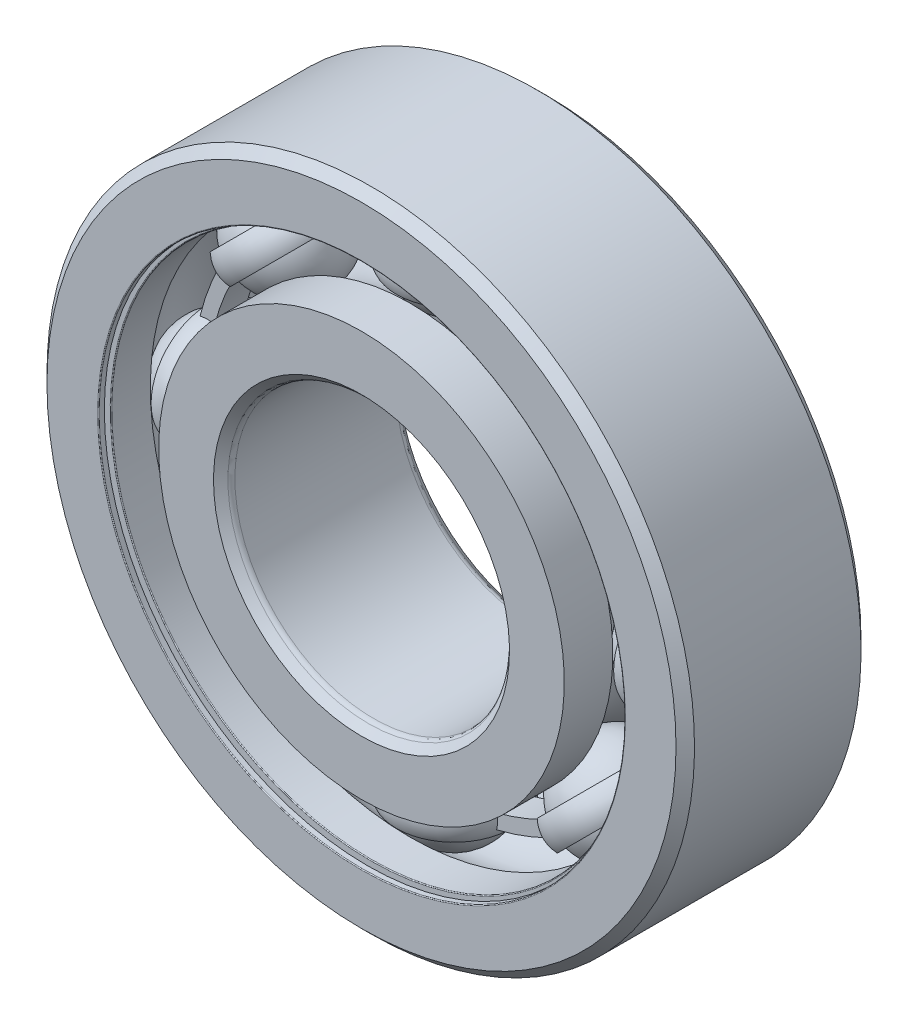
from build123d import *

# Parameters (mm, degrees)
BOSS_EXTRUDE1_DEPTH = 0.666666667
CIRPATTERN1_COUNT   = 8
CIRPATTERN2_COUNT   = 8
FILLET1_R           = 0.036
FILLET2_R           = 0.3


with BuildPart() as part:
    # Sketch3 → Revolve1 (revolve)
    with BuildSketch(Plane(origin=(0, 0, 0), x_dir=(0, 0, -1), z_dir=(1, 0, 0))):
        with BuildLine():
            Line((3.6, 14), (4, 13.6))
            Line((4, 13.6), (4, 11.230769231))
            Line((4, 11.230769231), (1.9, 11.230769231))
            ThreePointArc((1.9, 11.230769231), (0, 12.263800543), (-1.9, 11.230769231))
            Line((-1.9, 11.230769231), (-4, 11.230769231))
            Line((-4, 11.230769231), (-4, 13.6))
            Line((-4, 13.6), (-3.6, 14))
            Line((-3.6, 14), (3.6, 14))
        make_face()
    revolve(axis=Axis((0, 0, 4), (0, 0, -1)))

    # Sketch8 → Cut-Revolve1 (revolve, cut)
    with BuildSketch(Plane(origin=(0, 0, 0), x_dir=(0, 0, -1), z_dir=(1, 0, 0))):
        Polygon((-3.744, 11.230769231), (-3.6, 11.230769231), (-3.6, 12.153846154), (-3.744, 12.153846154), (-3.744, 11.374769231), (-4, 11.374769231), (-4, 11.230769231), align=None)
        Polygon((3.6, 11.230769231), (3.744, 11.230769231), (4, 11.230769231), (4, 11.374769231), (3.744, 11.374769231), (3.744, 12.153846154), (3.6, 12.153846154), align=None)
    revolve(axis=Axis((0, 0, 4), (0, 0, -1)), mode=Mode.SUBTRACT)

    # Fillet1
    fillet1_edges = [part.edges().sort_by_distance(p)[0] for p in [
        (0, -11.230769231, -3.6),
        (0, -11.374769231, -4),
        (0, -11.230769231, 3.6),
        (0, -11.374769231, 4),
    ]]
    fillet(fillet1_edges, radius=FILLET1_R)


with BuildPart() as body_2:
    # Sketch4 → Revolve2 (revolve)
    with BuildSketch(Plane(origin=(0, 0, 0), x_dir=(0, 0, -1), z_dir=(1, 0, 0))):
        with BuildLine():
            Line((-3.6, 6), (-4, 6.4))
            Line((-4, 6.4), (-4, 8.769230769))
            Line((-4, 8.769230769), (-1.9, 8.769230769))
            ThreePointArc((-1.9, 8.769230769), (0, 7.736199457), (1.9, 8.769230769))
            Line((1.9, 8.769230769), (4, 8.769230769))
            Line((4, 8.769230769), (4, 6.4))
            Line((4, 6.4), (3.6, 6))
            Line((3.6, 6), (-3.6, 6))
        make_face()
    revolve(axis=Axis((0, 0, 4), (0, 0, -1)))

    # Fillet2
    fillet2_edges = [body_2.edges().sort_by_distance(p)[0] for p in [
        (0, -6, -3.6),
        (0, -6, 3.6),
    ]]
    fillet(fillet2_edges, radius=FILLET2_R)


with BuildPart() as body_3:
    # Sketch5 → Revolve3 (revolve)
    with BuildSketch(Plane(origin=(0, 0, 0), x_dir=(0, 0, -1), z_dir=(1, 0, 0))):
        with BuildLine():
            Line((-2.263800543, 10), (2.263800543, 10))
            ThreePointArc((2.263800543, 10), (0, 12.263800543), (-2.263800543, 10))
        make_face()
    revolve(axis=Axis((0, 10, 2.263800543), (0, 0, -1)))


with BuildPart() as body_4:
    # Sketch6 → Revolve4 (revolve)
    with BuildSketch(Plane(origin=(0, 0, 0), x_dir=(0, 0, -1), z_dir=(1, 0, 0))):
        with BuildLine():
            Line((-2.178553344, 10.615384615), (-2.482127787, 10.615384615))
            ThreePointArc((-2.482127787, 10.615384615), (-2.633915008, 10), (-2.482127787, 9.384615385))
            Line((-2.482127787, 9.384615385), (-2.178553344, 9.384615385))
            ThreePointArc((-2.178553344, 9.384615385), (-2.263800543, 10), (-2.178553344, 10.615384615))
        make_face()
    revolve4 = revolve(axis=Axis((0, 14, 0), (0, -1, 0)))

    # Sketch7 → Boss-Extrude1 (add, symmetric)
    with BuildSketch(Plane.XY):
        with BuildLine():
            Line((7.071067812, 7.071067812), (7.506210446, 7.506210446))
            ThreePointArc((7.506210446, 7.506210446), (4.06233182, 9.807336576), (0, 10.615384615))
            Line((0, 10.615384615), (0, 10))
            ThreePointArc((0, 10), (3.826834324, 9.238795325), (7.071067812, 7.071067812))
        make_face()
    boss_extrude1 = extrude(amount=BOSS_EXTRUDE1_DEPTH, both=True)

    # CirPattern2: Revolve4, Boss-Extrude1 ×8 about axis
    cirpattern2_axis = Axis((0, 0, 4), (0, 0, -1))
    add([revolve4.rotate(cirpattern2_axis, i * 360 / CIRPATTERN2_COUNT) for i in range(1, CIRPATTERN2_COUNT)])
    add([boss_extrude1.rotate(cirpattern2_axis, i * 360 / CIRPATTERN2_COUNT) for i in range(1, CIRPATTERN2_COUNT)])


with BuildPart() as cirpattern1_1:
    # CirPattern1: pattern copy
    add(body_3.part.rotate(Axis((0, 0, 4), (0, 0, -1)), 1 * 360 / CIRPATTERN1_COUNT))


with BuildPart() as cirpattern1_2:
    # CirPattern1: pattern copy
    add(body_3.part.rotate(Axis((0, 0, 4), (0, 0, -1)), 2 * 360 / CIRPATTERN1_COUNT))


with BuildPart() as cirpattern1_3:
    # CirPattern1: pattern copy
    add(body_3.part.rotate(Axis((0, 0, 4), (0, 0, -1)), 3 * 360 / CIRPATTERN1_COUNT))


with BuildPart() as cirpattern1_4:
    # CirPattern1: pattern copy
    add(body_3.part.rotate(Axis((0, 0, 4), (0, 0, -1)), 4 * 360 / CIRPATTERN1_COUNT))


with BuildPart() as cirpattern1_5:
    # CirPattern1: pattern copy
    add(body_3.part.rotate(Axis((0, 0, 4), (0, 0, -1)), 5 * 360 / CIRPATTERN1_COUNT))


with BuildPart() as cirpattern1_6:
    # CirPattern1: pattern copy
    add(body_3.part.rotate(Axis((0, 0, 4), (0, 0, -1)), 6 * 360 / CIRPATTERN1_COUNT))


with BuildPart() as cirpattern1_7:
    # CirPattern1: pattern copy
    add(body_3.part.rotate(Axis((0, 0, 4), (0, 0, -1)), 7 * 360 / CIRPATTERN1_COUNT))


solid = Compound([part.part, body_2.part, body_3.part, body_4.part, cirpattern1_1.part, cirpattern1_2.part, cirpattern1_3.part, cirpattern1_4.part, cirpattern1_5.part, cirpattern1_6.part, cirpattern1_7.part])
